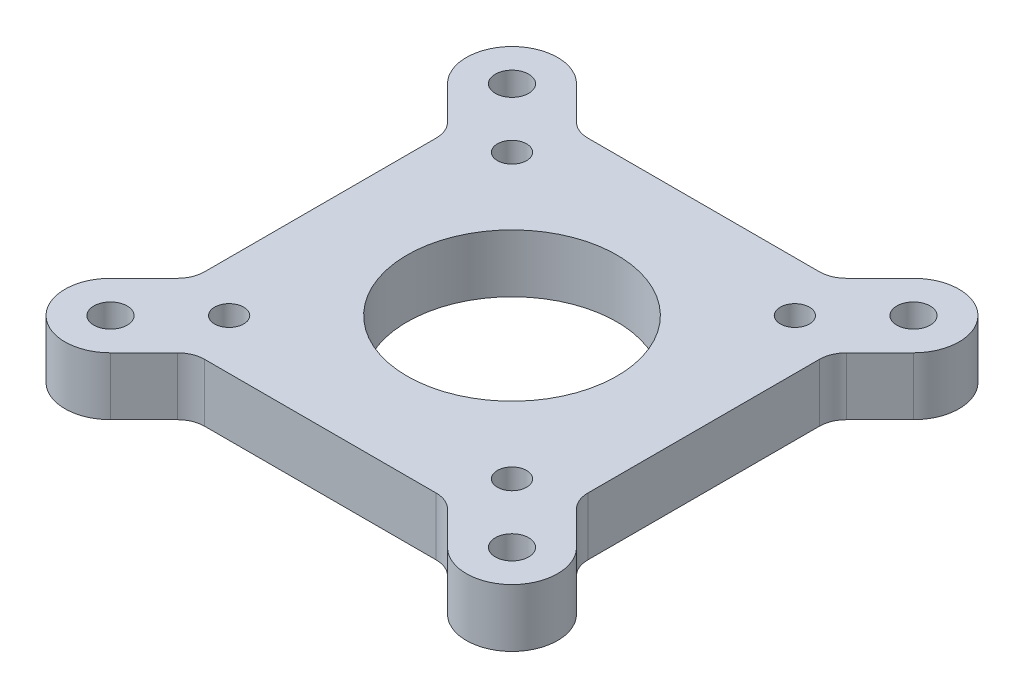
from build123d import *

# Parameters (mm, degrees)
SKETCH1_W             = 42
SKETCH1_H             = 42
BOSS_EXTRUDE1_DEPTH   = 6.35
M3_CLEARANCE_HOLE1_D  = 3.2
SKETCH6_R             = 11.5
CUT_EXTRUDE1_DEPTH    = 31.369762923
BOSS_EXTRUDE2_DEPTH   = 6.35
F_6_CLEARANCE_HOLE1_D = 3.6576
CIRPATTERN2_COUNT     = 4
FILLET2_R             = 3


with BuildPart() as part:
    # Sketch1 → Boss-Extrude1 (new body)
    with BuildSketch(Plane(origin=(0, 0, 0), x_dir=(1, 0, 0), z_dir=(0, 1, 0))):
        Rectangle(SKETCH1_W, SKETCH1_H)
    extrude(amount=BOSS_EXTRUDE1_DEPTH)

    # M3 Clearance Hole1 (through all)
    with Locations(Plane(origin=(0, 6.35, 0), x_dir=(1, 0, 0), z_dir=(0, 1, 0))):
        with Locations((-15.5, 15.5), (-15.5, -15.5), (15.5, -15.5), (15.5, 15.5)):
            Hole(M3_CLEARANCE_HOLE1_D / 2)

    # Sketch6 → Cut-Extrude1 (cut, through all)
    with BuildSketch(Plane(origin=(0, 6.35, 0), x_dir=(1, 0, 0), z_dir=(0, 1, 0))):
        Circle(SKETCH6_R)
    extrude(amount=-CUT_EXTRUDE1_DEPTH, mode=Mode.SUBTRACT)

    # Sketch7 → Boss-Extrude2 (add)
    with BuildSketch(Plane(origin=(0, 6.35, 0), x_dir=(1, 0, 0), z_dir=(0, 1, 0))):
        with BuildLine():
            Line((-25.535533906, 18.464466094), (-21, 13.928932188))
            Line((-21, 13.928932188), (-21, 21))
            Line((-21, 21), (-13.928932188, 21))
            Line((-13.928932188, 21), (-18.464466094, 25.535533906))
            ThreePointArc((-18.464466094, 25.535533906), (-25.535533906, 25.535533906), (-25.535533906, 18.464466094))
        make_face()
    boss_extrude2 = extrude(amount=-BOSS_EXTRUDE2_DEPTH)

    # 6 Clearance Hole1 (through all)
    with Locations(Plane(origin=(0, 6.35, 0), x_dir=(1, 0, 0), z_dir=(0, 1, 0))):
        with Locations((-22, 22)):
            f_6_clearance_hole1 = Hole(F_6_CLEARANCE_HOLE1_D / 2)

    # CirPattern2: Boss-Extrude2, 6 Clearance Hole1 ×4 about axis
    cirpattern2_axis = Axis((0, 0, 0), (0, 1, 0))
    add([boss_extrude2.rotate(cirpattern2_axis, i * 360 / CIRPATTERN2_COUNT) for i in range(1, CIRPATTERN2_COUNT)])
    add([f_6_clearance_hole1.rotate(cirpattern2_axis, i * 360 / CIRPATTERN2_COUNT) for i in range(1, CIRPATTERN2_COUNT)], mode=Mode.SUBTRACT)

    # Fillet2
    fillet2_edges = [part.edges().sort_by_distance(p)[0] for p in [
        (13.928932188, 3.175, -21),
        (21, 3.175, -13.928932188),
        (21, 3.175, 13.928932188),
        (13.928932188, 3.175, 21),
        (-13.928932188, 3.175, 21),
        (-21, 3.175, 13.928932188),
        (-21, 3.175, -13.928932188),
        (-13.928932188, 3.175, -21),
    ]]
    fillet(fillet2_edges, radius=FILLET2_R)


solid = part.part
